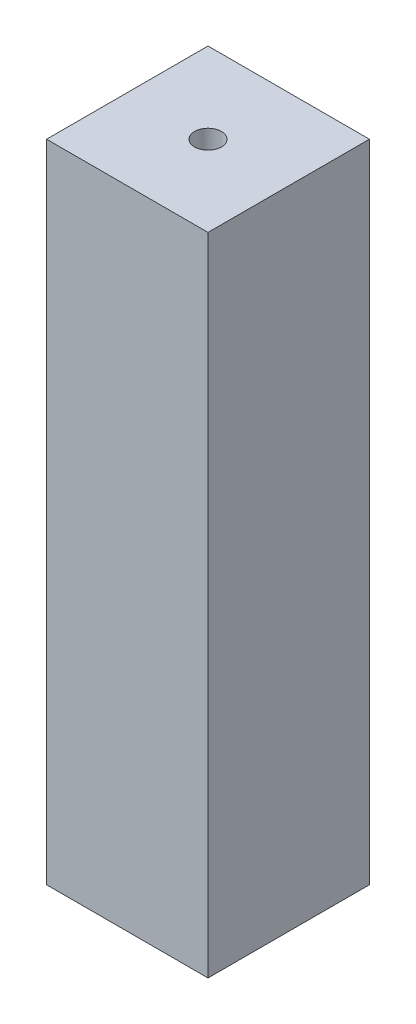
from build123d import *

# Parameters (mm, degrees)
SKETCH1_W           = 15
SKETCH1_H           = 15
BOSS_EXTRUDE1_DEPTH = 60
SKETCH2_R           = 1.25
CUT_EXTRUDE1_DEPTH  = 61


with BuildPart() as part:
    # Sketch1 → Boss-Extrude1 (new body)
    with BuildSketch(Plane(origin=(0, 0, 0), x_dir=(1, 0, 0), z_dir=(0, 1, 0))):
        with Locations((7.5, 7.5)):
            Rectangle(SKETCH1_W, SKETCH1_H)
    extrude(amount=BOSS_EXTRUDE1_DEPTH)

    # Sketch2 → Cut-Extrude1 (cut, through all)
    with BuildSketch(Plane(origin=(0, 60, 0), x_dir=(1, 0, 0), z_dir=(0, 1, 0))):
        with Locations((7.5, 7.5)):
            Circle(SKETCH2_R)
    extrude(amount=-CUT_EXTRUDE1_DEPTH, mode=Mode.SUBTRACT)


solid = part.part
